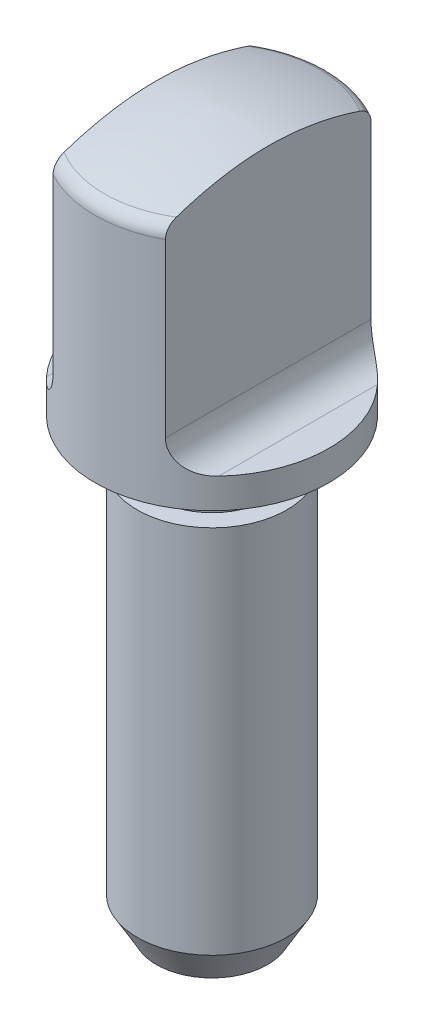
from build123d import *

# Parameters (mm, degrees)
CUT_EXTRUDE1_DEPTH      = 40.103215572
CUT_EXTRUDE1_DEPTH_BACK = 40.103215572
CHAMFER1_SIZE           = 1.016
CHAMFER1_SIZE2          = 1.75976362
FILLET1_R               = 0.79375


with BuildPart() as part:
    # Sketch1 → Revolve1 (revolve)
    with BuildSketch(Plane.XY, mode=Mode.PRIVATE) as revolve1_sk:
        with BuildLine():
            Line((6.223, 36.649006265), (6.223, 23.8125))
            Line((6.223, 23.8125), (2.9845, 23.8125))
            Line((2.9845, 23.8125), (2.9845, 21.43125))
            Line((2.9845, 21.43125), (3.96875, 21.43125))
            Line((3.96875, 21.43125), (3.96875, 0))
            Line((3.96875, 0), (0, 0))
            Line((0, 0), (0, 38.1))
            ThreePointArc((0, 38.1), (3.175227984, 37.647818746), (6.223, 36.649006265))
        make_face()
    revolve(revolve1_sk.sketch.rotate(Axis((0, 0, 0), (0, 1, 0)), 90), axis=Axis((0, 0, 0), (0, 1, 0)))

    # Sketch2 → Cut-Extrude1 (cut, two sides: drawn at the far end of the back side and taken through both)
    with BuildSketch(Plane.XY.offset(-CUT_EXTRUDE1_DEPTH_BACK)):
        with BuildLine():
            Line((-6.223, 25.4), (-4.572, 25.4))
            ThreePointArc((-4.572, 25.4), (-3.449467985, 25.864967985), (-2.9845, 26.9875))
            Line((-2.9845, 26.9875), (-2.9845, 38.1))
            Line((-2.9845, 38.1), (-6.223, 38.1))
            Line((-6.223, 38.1), (-6.223, 25.4))
        make_face()
        with BuildLine():
            Line((6.223, 38.1), (6.223, 25.4))
            Line((6.223, 25.4), (4.572, 25.4))
            ThreePointArc((4.572, 25.4), (3.449467985, 25.864967985), (2.9845, 26.9875))
            Line((2.9845, 26.9875), (2.9845, 38.1))
            Line((2.9845, 38.1), (6.223, 38.1))
        make_face()
    extrude(amount=CUT_EXTRUDE1_DEPTH + CUT_EXTRUDE1_DEPTH_BACK, mode=Mode.SUBTRACT)

    # Chamfer1
    chamfer1_edges = [part.edges().sort_by_distance(p)[0] for p in [
        (0, 0, 3.96875),
    ]]
    chamfer1_side = [part.faces().sort_by_distance(p)[0] for p in [
        (0, 0, 0),
    ]]
    chamfer(chamfer1_edges, length=CHAMFER1_SIZE, length2=CHAMFER1_SIZE2, reference=chamfer1_side[0])

    # Fillet1
    fillet1_edges = [part.edges().sort_by_distance(p)[0] for p in [
        (1.540166147, 36.649006265, -6.029396092),
        (0, 36.649006265, 6.223),
    ]]
    fillet(fillet1_edges, radius=FILLET1_R)


solid = part.part
